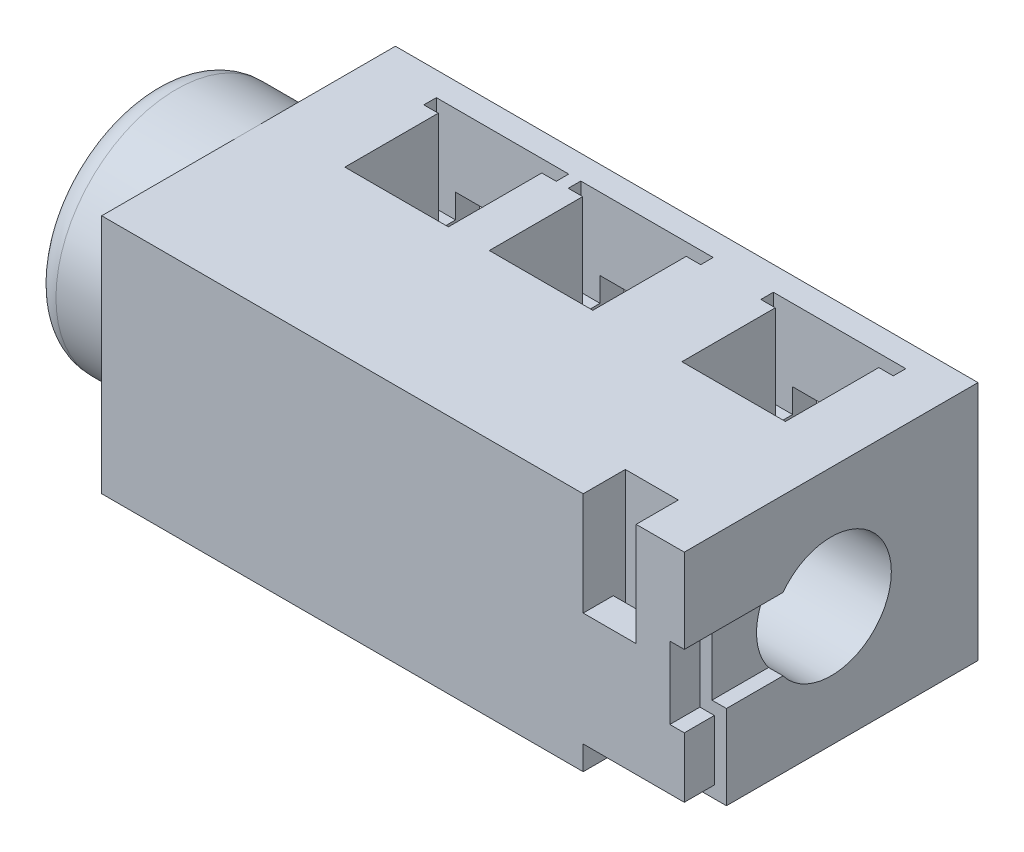
from build123d import *

# Parameters (mm, degrees)
SKETCH_1_W          = 12.1
SKETCH_1_H          = 6.1
EXTRUDE_1_DEPTH     = 5
SKETCH_3_R          = 2.5
EXTRUDE_2_DEPTH     = 2
SKETCH_4_R          = 0.75
EXTRUDE_3_DEPTH     = 1
FILLET_1_R          = 0.5
CUT_EXTRUDE_START   = -0.875
CUT_EXTRUDE_2_DEPTH = 0.875
CUT_EXTRUDE_4_DEPTH = 2
FILLET_2_R          = 0.5
SKETCH_10_W         = 1.1
SKETCH_10_H         = 2.146086497
SKETCH_10_W_2       = 2.1
SKETCH_10_H_2       = 0.5
SKETCH_10_W_3       = 0.3
SKETCH_10_H_3       = 1.5
CUT_EXTRUDE_5_DEPTH = 0.875
SKETCH_11_W         = 2.1
SKETCH_11_H         = 0.25
CUT_EXTRUDE_6_DEPTH = 3.25
SKETCH_12_W         = 0.3
SKETCH_12_H         = 1.5
CUT_EXTRUDE_7_DEPTH = 3


with BuildPart() as part:
    # 草图1 → 凸台-拉伸1 (new body)
    with BuildSketch(Plane(origin=(0, 0, 0), x_dir=(1, 0, 0), z_dir=(0, 1, 0))):
        with Locations((6.05, 0)):
            Rectangle(SKETCH_1_W, SKETCH_1_H)
    extrude(amount=EXTRUDE_1_DEPTH)

    # 草图3 → 凸台-拉伸2 (add)
    with BuildSketch(Plane.ZY):
        with Locations((0, 2.5)):
            Circle(SKETCH_3_R)
    extrude(amount=EXTRUDE_2_DEPTH)

    # 草图4 → 凸台-拉伸3 (add)
    with BuildSketch(Plane.XZ):
        with Locations((1.6, 0)):
            Circle(SKETCH_4_R)
        with Locations((8.6, 0)):
            Circle(SKETCH_4_R)
    extrude(amount=EXTRUDE_3_DEPTH)

    # 圆角1
    fillet_1_edges = [part.edges().sort_by_distance(p)[0] for p in [
        (0.85, -1, 0),
        (7.85, -1, 0),
    ]]
    fillet(fillet_1_edges, radius=FILLET_1_R)

    # 草图6 → 切除-拉伸2 (cut)
    with BuildSketch(Plane(origin=(0, 0, -3.05), x_dir=(-1, 0, 0), z_dir=(0, 0, -1)).offset(CUT_EXTRUDE_START)):
        Polygon((-1.75, 0), (-1.75, 3.5), (-2.615259451, 3.5), (-2.615259451, 0.5), (-3.7, 0.5), (-3.7, 0), align=None)
        Polygon((-6.7, 0.5), (-6.7, 0), (-4.75, 0), (-4.75, 3.5), (-5.615259451, 3.5), (-5.615259451, 0.5), align=None)
        Polygon((-8.75, 3.5), (-9.615259451, 3.5), (-9.615259451, 0.5), (-10.7, 0.5), (-10.7, 0), (-8.75, 0), align=None)
    extrude(amount=CUT_EXTRUDE_2_DEPTH, mode=Mode.SUBTRACT)

    # 草图8 → 切除-拉伸4 (cut)
    with BuildSketch(Plane(origin=(0, 5, 0), x_dir=(1, 0, 0), z_dir=(0, 1, 0))):
        Polygon((8.35, 2.55), (11.1, 2.55), (11.1, 2.290157714), (10.8, 2.290157714), (10.8, 0.35), (8.65, 0.35), (8.65, 2.290157714), (8.35, 2.290157714), align=None)
        Polygon((4.35, 2.55), (7.1, 2.55), (7.1, 2.290157714), (6.8, 2.290157714), (6.8, 0.35), (4.65, 0.35), (4.65, 2.290157714), (4.35, 2.290157714), align=None)
        Polygon((1.35, 2.55), (4.1, 2.55), (4.1, 2.290157714), (3.8, 2.290157714), (3.8, 0.35), (1.65, 0.35), (1.65, 2.290157714), (1.35, 2.290157714), align=None)
    extrude(amount=-CUT_EXTRUDE_4_DEPTH, mode=Mode.SUBTRACT)

    # 草图9 → 切除-旋转1 (revolve, cut)
    with BuildSketch(Plane(origin=(0, 2.5, 0), x_dir=(1, 0, 0), z_dir=(0, 1, 0))):
        Polygon((-2, 0), (-2, 1.8), (5, 1.8), (5, 1.5), (8, 1.5), (8, 1.25), (12.1, 1.25), (12.1, 0), align=None)
    revolve(axis=Axis((-0.907835796, 2.5, 0), (1, 0, 0)), mode=Mode.SUBTRACT)

    # 圆角2
    fillet_2_edges = [part.edges().sort_by_distance(p)[0] for p in [
        (-2, 2.5, -2.5),
    ]]
    fillet(fillet_2_edges, radius=FILLET_2_R)

    # 草图10 → 切除-拉伸5 (cut)
    with BuildSketch(Plane.XY.offset(3.05).offset(CUT_EXTRUDE_START)):
        with Locations((10.55, 3.926956752)):
            Rectangle(SKETCH_10_W, SKETCH_10_H)
        with Locations((11.05, 0.25)):
            Rectangle(SKETCH_10_W_2, SKETCH_10_H_2)
        with Locations((11.95, 2.5)):
            Rectangle(SKETCH_10_W_3, SKETCH_10_H_3)
    extrude(amount=CUT_EXTRUDE_5_DEPTH, mode=Mode.SUBTRACT)

    # 草图11 → 切除-拉伸6 (cut)
    with BuildSketch(Plane.XZ):
        with Locations((11.05, 2.3)):
            Rectangle(SKETCH_11_W, SKETCH_11_H)
    extrude(amount=-CUT_EXTRUDE_6_DEPTH, mode=Mode.SUBTRACT)

    # 草图12 → 切除-拉伸7 (cut)
    with BuildSketch(Plane.XY.offset(3.05)):
        with Locations((11.95, 2.5)):
            Rectangle(SKETCH_12_W, SKETCH_12_H)
    extrude(amount=-CUT_EXTRUDE_7_DEPTH, mode=Mode.SUBTRACT)


solid = part.part
